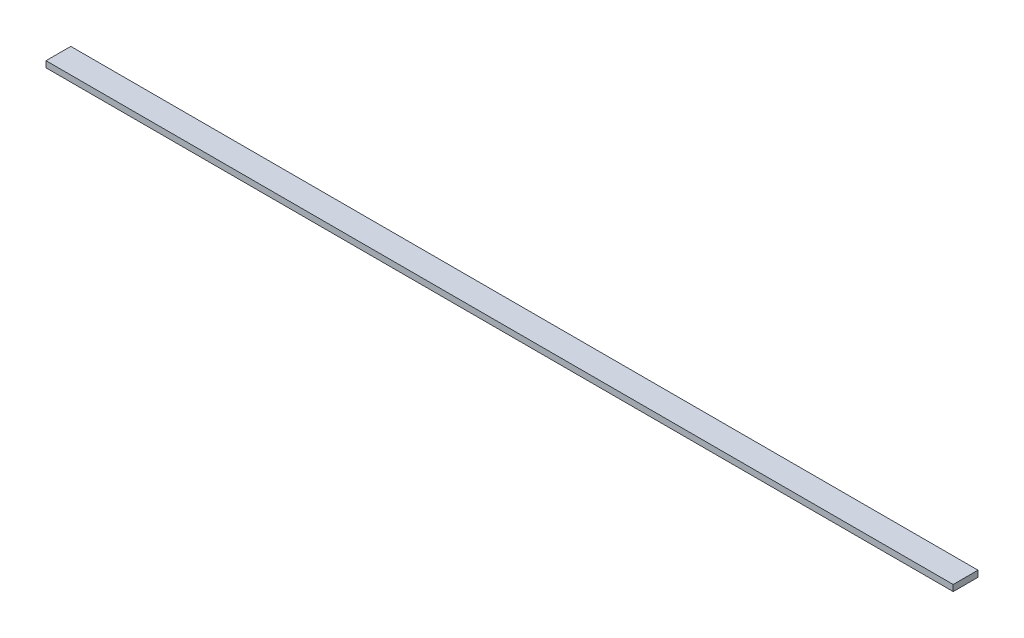
from build123d import *

# Parameters (mm, degrees)
SKETCH1_W           = 232.41
SKETCH1_H           = 6.35
BOSS_EXTRUDE1_DEPTH = 1.5875


with BuildPart() as part:
    # Sketch1 → Boss-Extrude1 (new body)
    with BuildSketch(Plane(origin=(0, 0, 0), x_dir=(1, 0, 0), z_dir=(0, 1, 0))):
        Rectangle(SKETCH1_W, SKETCH1_H)
    extrude(amount=BOSS_EXTRUDE1_DEPTH)


solid = part.part
